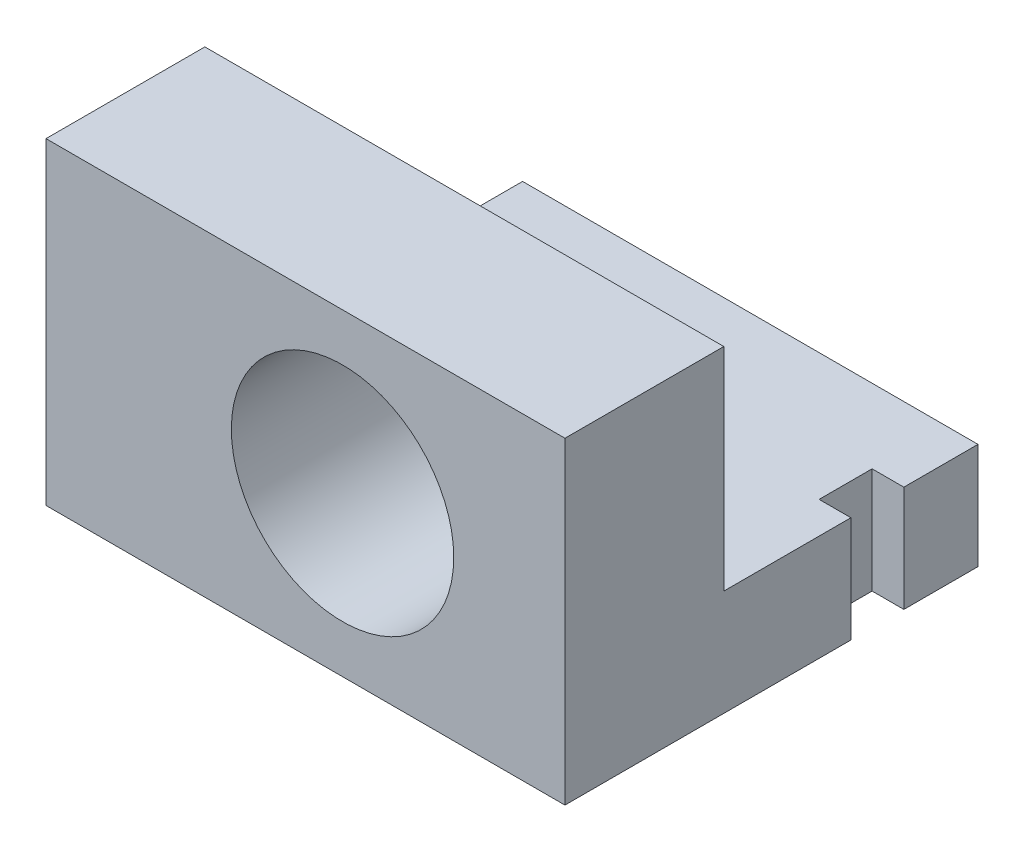
from build123d import *

# Parameters (mm, degrees)
SKETCH1_W           = 49
SKETCH1_H           = 30
BOSS_EXTRUDE1_DEPTH = 15
SKETCH3_R           = 10.5
CUT_EXTRUDE1_DEPTH  = 23
SKETCH4_W           = 43
SKETCH4_H           = 10
BOSS_EXTRUDE3_DEPTH = 24
SKETCH5_W           = 5
SKETCH5_H           = 10
CUT_EXTRUDE2_DEPTH  = 3


with BuildPart() as part:
    # Sketch1 → Boss-Extrude1 (new body)
    with BuildSketch(Plane.XY):
        Rectangle(SKETCH1_W, SKETCH1_H)
    extrude(amount=BOSS_EXTRUDE1_DEPTH)

    # Sketch3 → Cut-Extrude1 (cut)
    with BuildSketch(Plane(origin=(0, 0, 0), x_dir=(-1, 0, 0), z_dir=(0, 0, -1))):
        with Locations((-3.5, 0)):
            Circle(SKETCH3_R)
    extrude(amount=-CUT_EXTRUDE1_DEPTH, mode=Mode.SUBTRACT)

    # Sketch4 → Boss-Extrude3 (add)
    with BuildSketch(Plane(origin=(0, 0, 0), x_dir=(-1, 0, 0), z_dir=(0, 0, -1))):
        with Locations((-3, -10)):
            Rectangle(SKETCH4_W, SKETCH4_H)
    extrude(amount=BOSS_EXTRUDE3_DEPTH)

    # Sketch5 → Cut-Extrude2 (cut)
    with BuildSketch(Plane.ZY.offset(18.5)):
        with Locations((-14.5, -10)):
            Rectangle(SKETCH5_W, SKETCH5_H)
    cut_extrude2 = extrude(amount=-CUT_EXTRUDE2_DEPTH, mode=Mode.SUBTRACT)

    # Mirror1: Cut-Extrude2 across plane
    add(cut_extrude2.mirror(Plane.ZY.offset(-3)), mode=Mode.SUBTRACT)


solid = part.part
